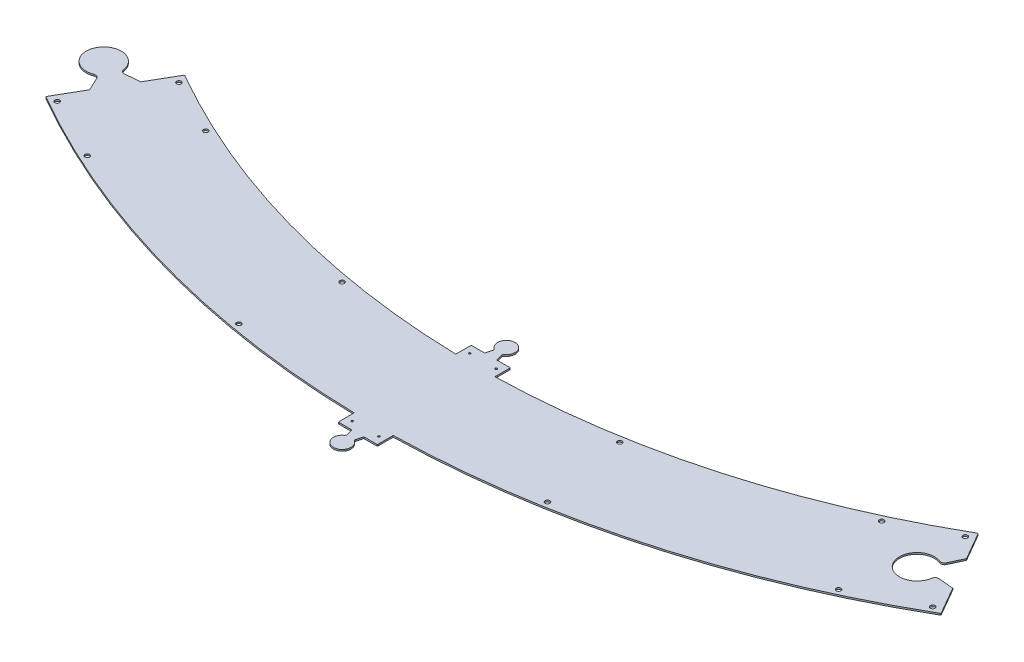
from build123d import *

# Parameters (mm, degrees)
SKETCH1_R           = 1.25
SKETCH1_R_2         = 3
BOSS_EXTRUDE2_DEPTH = 2
FILLET1_R           = 1
CUT_EXTRUDE1_DEPTH  = 2
BOSS_EXTRUDE3_DEPTH = 2


with BuildPart() as part:
    # Sketch1 → Boss-Extrude2 (new body)
    with BuildSketch(Plane(origin=(0, 0, 0), x_dir=(1, 0, 0), z_dir=(0, 1, 0))):
        with BuildLine():
            Line((507.5, -879.015784841), (572.5, -991.599087333))
            ThreePointArc((572.5, -991.599087333), (308.404936897, -1102.683723875), (25, -1144.7270417))
            Line((25, -1144.7270417), (25, -1165))
            Line((25, -1165), (-25, -1165))
            Line((-25, -1165), (-25, -1144.7270417))
            ThreePointArc((-25, -1144.7270417), (-308.404936897, -1102.683723875), (-572.5, -991.599087333))
            Line((-572.5, -991.599087333), (-507.5, -879.015784841))
            ThreePointArc((-507.5, -879.015784841), (-274.756394269, -977.104868378), (-25, -1014.692071517))
            Line((-25, -1014.692071517), (-25, -995))
            Line((-25, -995), (25, -995))
            Line((25, -995), (25, -1014.692071517))
            ThreePointArc((25, -1014.692071517), (274.756394269, -977.104868378), (507.5, -879.015784841))
        make_face()
        with Locations((-17, -1005)):
            Circle(SKETCH1_R, mode=Mode.SUBTRACT)
        with Locations((17, -1005)):
            Circle(SKETCH1_R, mode=Mode.SUBTRACT)
        with Locations((502.839745962, -890.943988071)):
            Circle(SKETCH1_R_2, mode=Mode.SUBTRACT)
        with Locations((559.839745962, -989.670884103)):
            Circle(SKETCH1_R_2, mode=Mode.SUBTRACT)
        with Locations((480.404221067, -1030.524519059)):
            Circle(SKETCH1_R_2, mode=Mode.SUBTRACT)
        with Locations((432.237043229, -927.200160947)):
            Circle(SKETCH1_R_2, mode=Mode.SUBTRACT)
        with Locations((-17, -1155)):
            Circle(SKETCH1_R, mode=Mode.SUBTRACT)
        with Locations((17, -1155)):
            Circle(SKETCH1_R, mode=Mode.SUBTRACT)
        with Locations((177.531862859, -1007.477760385)):
            Circle(SKETCH1_R_2, mode=Mode.SUBTRACT)
        with Locations((197.315472209, -1119.748009343)):
            Circle(SKETCH1_R_2, mode=Mode.SUBTRACT)
        with Locations((-559.839745962, -989.670884103)):
            Circle(SKETCH1_R_2, mode=Mode.SUBTRACT)
        with Locations((-502.839745962, -890.943988071)):
            Circle(SKETCH1_R_2, mode=Mode.SUBTRACT)
        with Locations((-480.404221067, -1030.524519059)):
            Circle(SKETCH1_R_2, mode=Mode.SUBTRACT)
        with Locations((-432.237043229, -927.200160947)):
            Circle(SKETCH1_R_2, mode=Mode.SUBTRACT)
        with Locations((-197.315472209, -1119.748009343)):
            Circle(SKETCH1_R_2, mode=Mode.SUBTRACT)
        with Locations((-177.531862859, -1007.477760385)):
            Circle(SKETCH1_R_2, mode=Mode.SUBTRACT)
    extrude(amount=BOSS_EXTRUDE2_DEPTH)

    # Fillet1
    fillet1_edges = [part.edges().sort_by_distance(p)[0] for p in [
        (25, 1, 1165),
        (-25, 1, 1165),
        (-572.5, 1, 991.599087333),
        (-507.5, 1, 879.015784841),
        (-25, 1, 995),
        (25, 1, 995),
        (507.5, 1, 879.015784841),
        (572.5, 1, 991.599087333),
    ]]
    fillet(fillet1_edges, radius=FILLET1_R)

    # Sketch3 → Cut-Extrude1 (cut)
    with BuildSketch(Plane(origin=(0, 2, 0), x_dir=(1, 0, 0), z_dir=(0, 1, 0))):
        with BuildLine():
            Line((519.871701126, -931.945073732), (527.997692321, -914.518829378))
            Line((527.997692321, -914.518829378), (552.001843085, -956.095238095))
            Line((552.001843085, -956.095238095), (532.847277184, -954.419430724))
            ThreePointArc((532.847277184, -954.419430724), (529.319600421, -955.471006493), (527.467771352, -958.652365329))
            ThreePointArc((527.467771352, -958.652365329), (485.99383482, -966.487373624), (513.516119308, -934.48739514))
            ThreePointArc((513.516119308, -934.48739514), (517.197171414, -934.474343541), (519.871701126, -931.945073732))
        make_face()
    extrude(amount=-CUT_EXTRUDE1_DEPTH, mode=Mode.SUBTRACT)

    # Sketch4 → Boss-Extrude3 (add)
    with BuildSketch(Plane(origin=(0, 2, 0), x_dir=(1, 0, 0), z_dir=(0, 1, 0))):
        with BuildLine():
            Line((-547.152258221, -916.194636749), (-527.997692321, -914.518829378))
            Line((-527.997692321, -914.518829378), (-552.001843085, -956.095238095))
            Line((-552.001843085, -956.095238095), (-560.12783428, -938.668993741))
            ThreePointArc((-560.12783428, -938.668993741), (-562.802363992, -936.139723932), (-566.483416097, -936.126672333))
            ThreePointArc((-566.483416097, -936.126672333), (-594.005700585, -904.126693849), (-552.531764054, -911.961702144))
            ThreePointArc((-552.531764054, -911.961702144), (-550.679934984, -915.14306098), (-547.152258221, -916.194636749))
        make_face()
        with BuildLine():
            Line((5.48633271, -986.815018385), (7.679491924, -995))
            Line((7.679491924, -995), (-7.679491924, -995))
            Line((-7.679491924, -995), (-5.48633271, -986.815018385))
            ThreePointArc((-5.48633271, -986.815018385), (-5.549842721, -985.31863757), (-6.457260037, -984.127091147))
            ThreePointArc((-6.457260037, -984.127091147), (0, -963.819660113), (6.457260037, -984.127091147))
            ThreePointArc((6.457260037, -984.127091147), (5.549842721, -985.31863757), (5.48633271, -986.815018385))
        make_face()
        with BuildLine():
            Line((-7.679491924, -1165), (7.679491924, -1165))
            Line((7.679491924, -1165), (5.48633271, -1173.184981615))
            ThreePointArc((5.48633271, -1173.184981615), (5.549842721, -1174.68136243), (6.457260037, -1175.872908853))
            ThreePointArc((6.457260037, -1175.872908853), (0, -1196.180339887), (-6.457260037, -1175.872908853))
            ThreePointArc((-6.457260037, -1175.872908853), (-5.549842721, -1174.68136243), (-5.48633271, -1173.184981615))
            Line((-5.48633271, -1173.184981615), (-7.679491924, -1165))
        make_face()
    extrude(amount=-BOSS_EXTRUDE3_DEPTH)


solid = part.part
